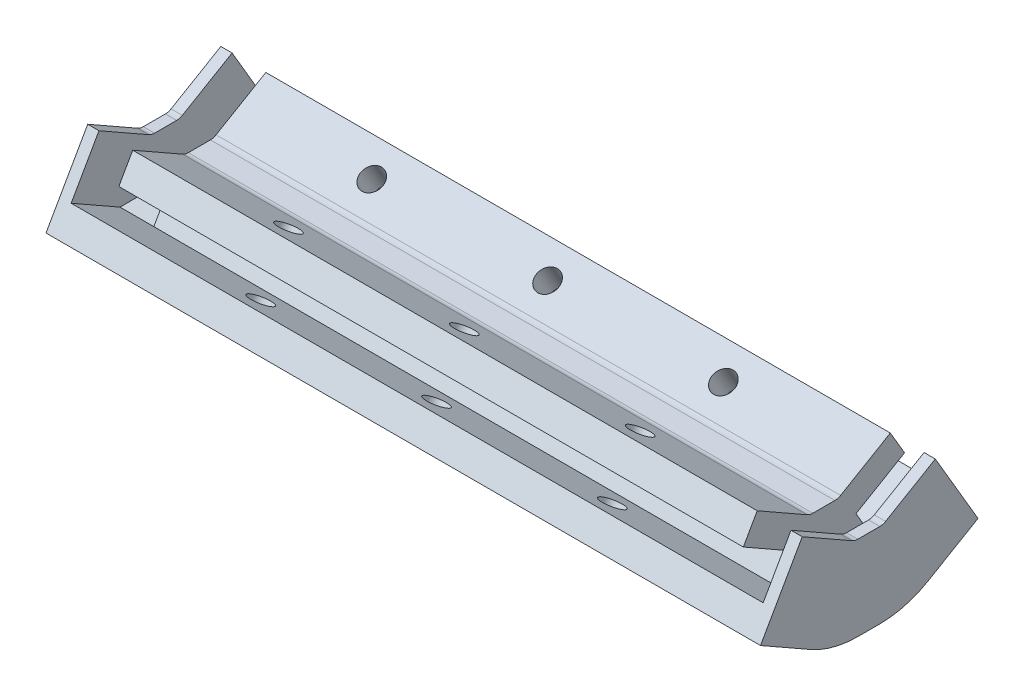
from build123d import *

# Parameters (mm, degrees)
SALIENTE_EXTRUIR1_DEPTH = 111
CROQUIS2_W              = 111
CROQUIS2_H              = 5
CORTAR_EXTRUIR1_DEPTH   = 5
CROQUIS3_W              = 111
CROQUIS3_H              = 5
CORTAR_EXTRUIR2_DEPTH   = 5
CROQUIS8_W              = 111
CROQUIS8_H              = 5
SALIENTE_EXTRUIR6_DEPTH = 5
CROQUIS9_W              = 111
CROQUIS9_H              = 5
SALIENTE_EXTRUIR7_DEPTH = 5
CROQUIS10_W             = 111
CROQUIS10_H             = 5
SALIENTE_EXTRUIR8_DEPTH = 5
CROQUIS11_W             = 111
CROQUIS11_H             = 5
SALIENTE_EXTRUIR9_DEPTH = 5
SALIENTE_EXTRUIR2_DEPTH = 8
SALIENTE_EXTRUIR3_DEPTH = 2
SALIENTE_EXTRUIR4_DEPTH = 8
SALIENTE_EXTRUIR5_DEPTH = 2
CROQUIS12_R             = 2
CORTAR_EXTRUIR3_DEPTH   = 16
CROQUIS13_R             = 4
CORTAR_EXTRUIR4_DEPTH   = 4
CROQUIS14_R             = 2
CORTAR_EXTRUIR5_DEPTH   = 16
CROQUIS15_R             = 4
CORTAR_EXTRUIR6_DEPTH   = 4


with BuildPart() as part:
    # Croquis1 → Saliente-Extruir1 (new body)
    with BuildSketch(Plane(origin=(0, 0, 0), x_dir=(0, 0, -1), z_dir=(1, 0, 0))):
        with BuildLine():
            Line((2.336042938, 2.185332004), (-2.204135338, 4.767752626))
            Line((-2.204135338, 4.767752626), (-7.148243501, -3.924530991))
            Line((-7.148243501, -3.924530991), (-2.608065225, -6.506951614))
            ThreePointArc((-2.608065225, -6.506951614), (0.256386453, -7.677264762), (3.32486457, -8.076211273))
            Line((3.32486457, -8.076211273), (7.253055883, -8.076211273))
            ThreePointArc((7.253055883, -8.076211273), (10.396202626, -7.657257363), (13.3198771, -6.429649364))
            Line((13.3198771, -6.429649364), (17.85154901, -3.774218091))
            Line((17.85154901, -3.774218091), (12.795864662, 4.853646985))
            Line((12.795864662, 4.853646985), (8.264192752, 2.198215712))
            ThreePointArc((8.264192752, 2.198215712), (7.776913673, 1.993614379), (7.253055883, 1.923788727))
            Line((7.253055883, 1.923788727), (3.32486457, 1.923788727))
            ThreePointArc((3.32486457, 1.923788727), (2.813451551, 1.990279812), (2.336042938, 2.185332004))
        make_face()
        with BuildLine():
            Line((-2.608065225, -6.506951614), (-7.148243501, -3.924530991))
            Line((-7.148243501, -3.924530991), (-9.620297582, -8.270672799))
            Line((-9.620297582, -8.270672799), (-5.080119306, -10.853093422))
            ThreePointArc((-5.080119306, -10.853093422), (-1.022146096, -12.511037048), (3.32486457, -13.076211273))
            Line((3.32486457, -13.076211273), (7.253055883, -13.076211273))
            ThreePointArc((7.253055883, -13.076211273), (11.705847103, -12.482693234), (15.847719275, -10.743581902))
            Line((15.847719275, -10.743581902), (20.379391184, -8.088150629))
            Line((20.379391184, -8.088150629), (17.85154901, -3.774218091))
            Line((17.85154901, -3.774218091), (13.3198771, -6.429649364))
            ThreePointArc((13.3198771, -6.429649364), (10.396202626, -7.657257363), (7.253055883, -8.076211273))
            Line((7.253055883, -8.076211273), (3.32486457, -8.076211273))
            ThreePointArc((3.32486457, -8.076211273), (0.256386453, -7.677264762), (-2.608065225, -6.506951614))
        make_face()
    extrude(amount=SALIENTE_EXTRUIR1_DEPTH)

    # Croquis2 → Cortar-Extruir1 (cut)
    with BuildSketch(Plane(origin=(0, 6.822115228, -11.642398074), x_dir=(1, 0, 0), z_dir=(0, 0.505568435, -0.862786508))):
        with Locations((55.5, 9.781524138)):
            Rectangle(CROQUIS2_W, CROQUIS2_H)
    extrude(amount=-CORTAR_EXTRUIR1_DEPTH, mode=Mode.SUBTRACT)

    # Croquis3 → Cortar-Extruir2 (cut)
    with BuildSketch(Plane(origin=(0, 2.112679425, 3.714321805), x_dir=(1, 0, 0), z_dir=(0, 0.494410816, 0.869228362))):
        with Locations((55.5, -4.445482547)):
            Rectangle(CROQUIS3_W, CROQUIS3_H)
    extrude(amount=-CORTAR_EXTRUIR2_DEPTH, mode=Mode.SUBTRACT)

    # Croquis8 → Saliente-Extruir6 (add)
    with BuildSketch(Plane(origin=(0, 2.112679425, 3.714321805), x_dir=(1, 0, 0), z_dir=(0, 0.494410816, 0.869228362))):
        with Locations((55.5, 0.554517453)):
            Rectangle(CROQUIS8_W, CROQUIS8_H)
    extrude(amount=SALIENTE_EXTRUIR6_DEPTH)

    # Croquis9 → Saliente-Extruir7 (add)
    with BuildSketch(Plane(origin=(0, 2.112679425, 3.714321805), x_dir=(1, 0, 0), z_dir=(0, 0.494410816, 0.869228362))):
        with Locations((55.5, -9.445482547)):
            Rectangle(CROQUIS9_W, CROQUIS9_H)
    extrude(amount=SALIENTE_EXTRUIR7_DEPTH)

    # Croquis10 → Saliente-Extruir8 (add)
    with BuildSketch(Plane(origin=(0, 6.822115228, -11.642398074), x_dir=(-1, 0, 0), z_dir=(0, 0.505568435, -0.862786508))):
        with Locations((-55.5, -4.781524138)):
            Rectangle(CROQUIS10_W, CROQUIS10_H)
    extrude(amount=SALIENTE_EXTRUIR8_DEPTH)

    # Croquis11 → Saliente-Extruir9 (add)
    with BuildSketch(Plane(origin=(0, 6.822115228, -11.642398074), x_dir=(-1, 0, 0), z_dir=(0, 0.505568435, -0.862786508))):
        with Locations((-55.5, -14.781524138)):
            Rectangle(CROQUIS11_W, CROQUIS11_H)
    extrude(amount=SALIENTE_EXTRUIR9_DEPTH)

    # Croquis4 → Saliente-Extruir2 (add)
    with BuildSketch(Plane.ZY):
        with BuildLine():
            Line((2.802101692, -6.396585072), (-13.537616472, -6.302060265))
            Line((-13.537616472, -6.302060265), (-22.165481548, -1.246375917))
            Line((-22.165481548, -1.246375917), (-24.693323722, -5.560308455))
            Line((-24.693323722, -5.560308455), (-15.847719275, -10.743581902))
            ThreePointArc((-15.847719275, -10.743581902), (-11.705847103, -12.482693234), (-7.253055883, -13.076211273))
            Line((-7.253055883, -13.076211273), (-3.32486457, -13.076211273))
            ThreePointArc((-3.32486457, -13.076211273), (1.022146096, -12.511037048), (5.080119306, -10.853093422))
            Line((5.080119306, -10.853093422), (13.96643939, -5.798618718))
            Line((13.96643939, -5.798618718), (11.494385309, -1.452476909))
            Line((11.494385309, -1.452476909), (2.802101692, -6.396585072))
        make_face()
    extrude(amount=SALIENTE_EXTRUIR2_DEPTH)

    # Croquis5 → Saliente-Extruir3 (add)
    with BuildSketch(Plane.ZY.offset(8)):
        with BuildLine():
            Line((-8.264192752, 2.198215712), (-17.1097972, 7.381489159))
            Line((-17.1097972, 7.381489159), (-22.165481548, -1.246375917))
            Line((-22.165481548, -1.246375917), (-13.537616472, -6.302060265))
            Line((-13.537616472, -6.302060265), (2.802101692, -6.396585072))
            Line((2.802101692, -6.396585072), (11.494385309, -1.452476909))
            Line((11.494385309, -1.452476909), (6.550277147, 7.239806708))
            Line((6.550277147, 7.239806708), (-2.336042938, 2.185332004))
            ThreePointArc((-2.336042938, 2.185332004), (-2.813451551, 1.990279812), (-3.32486457, 1.923788727))
            Line((-3.32486457, 1.923788727), (-7.253055883, 1.923788727))
            ThreePointArc((-7.253055883, 1.923788727), (-7.776913673, 1.993614379), (-8.264192752, 2.198215712))
        make_face()
    extrude(amount=-SALIENTE_EXTRUIR3_DEPTH)

    # Croquis6 → Saliente-Extruir4 (add)
    with BuildSketch(Plane(origin=(111, 0, 0), x_dir=(0, 0, -1), z_dir=(1, 0, 0))):
        with BuildLine():
            Line((13.537616472, -6.302060265), (-2.802101692, -6.396585072))
            Line((-2.802101692, -6.396585072), (-11.494385309, -1.452476909))
            Line((-11.494385309, -1.452476909), (-13.96643939, -5.798618718))
            Line((-13.96643939, -5.798618718), (-5.080119306, -10.853093422))
            ThreePointArc((-5.080119306, -10.853093422), (-1.022146096, -12.511037048), (3.32486457, -13.076211273))
            Line((3.32486457, -13.076211273), (7.253055883, -13.076211273))
            ThreePointArc((7.253055883, -13.076211273), (11.705847103, -12.482693234), (15.847719275, -10.743581902))
            Line((15.847719275, -10.743581902), (24.693323722, -5.560308455))
            Line((24.693323722, -5.560308455), (22.165481548, -1.246375917))
            Line((22.165481548, -1.246375917), (13.537616472, -6.302060265))
        make_face()
    extrude(amount=SALIENTE_EXTRUIR4_DEPTH)

    # Croquis7 → Saliente-Extruir5 (add)
    with BuildSketch(Plane(origin=(119, 0, 0), x_dir=(0, 0, -1), z_dir=(1, 0, 0))):
        with BuildLine():
            Line((22.165481548, -1.246375917), (17.1097972, 7.381489159))
            Line((17.1097972, 7.381489159), (8.264192752, 2.198215712))
            ThreePointArc((8.264192752, 2.198215712), (7.776913673, 1.993614379), (7.253055883, 1.923788727))
            Line((7.253055883, 1.923788727), (3.32486457, 1.923788727))
            ThreePointArc((3.32486457, 1.923788727), (2.813451551, 1.990279812), (2.336042938, 2.185332004))
            Line((2.336042938, 2.185332004), (-6.550277147, 7.239806708))
            Line((-6.550277147, 7.239806708), (-11.494385309, -1.452476909))
            Line((-11.494385309, -1.452476909), (-2.802101692, -6.396585072))
            Line((-2.802101692, -6.396585072), (13.537616472, -6.302060265))
            Line((13.537616472, -6.302060265), (22.165481548, -1.246375917))
        make_face()
    extrude(amount=-SALIENTE_EXTRUIR5_DEPTH)

    # Croquis12 → Cortar-Extruir3 (cut)
    with BuildSketch(Plane(origin=(0, -10.383352224, 5.905975776), x_dir=(-1, 0, 0), z_dir=(0, -0.869228362, 0.494410816))):
        with Locations((-23.25, -4.16151121)):
            Circle(CROQUIS12_R)
        with Locations((-54.5, -4.16151121)):
            Circle(CROQUIS12_R)
        with Locations((-85.75, -4.16151121)):
            Circle(CROQUIS12_R)
    extrude(amount=-CORTAR_EXTRUIR3_DEPTH, mode=Mode.SUBTRACT)

    # Croquis13 → Cortar-Extruir4 (cut)
    with BuildSketch(Plane(origin=(0, -10.383352224, 5.905975776), x_dir=(1, 0, 0), z_dir=(0, -0.869228362, 0.494410816))):
        with Locations((23.25, 4.16151121)):
            Circle(CROQUIS13_R)
        with Locations((54.5, 4.16151121)):
            Circle(CROQUIS13_R)
        with Locations((85.75, 4.16151121)):
            Circle(CROQUIS13_R)
    extrude(amount=-CORTAR_EXTRUIR4_DEPTH, mode=Mode.SUBTRACT)

    # Croquis14 → Cortar-Extruir5 (cut)
    with BuildSketch(Plane(origin=(0, -14.910265857, -8.73699311), x_dir=(-1, 0, 0), z_dir=(0, -0.862786508, -0.505568435))):
        with Locations((-23.25, 13.367766286)):
            Circle(CROQUIS14_R)
        with Locations((-54.5, 13.367766286)):
            Circle(CROQUIS14_R)
        with Locations((-85.75, 13.367766286)):
            Circle(CROQUIS14_R)
    extrude(amount=-CORTAR_EXTRUIR5_DEPTH, mode=Mode.SUBTRACT)

    # Croquis15 → Cortar-Extruir6 (cut)
    with BuildSketch(Plane(origin=(0, -14.910265857, -8.73699311), x_dir=(1, 0, 0), z_dir=(0, -0.862786508, -0.505568435))):
        with Locations((23.25, -13.367766286)):
            Circle(CROQUIS15_R)
        with Locations((54.5, -13.367766286)):
            Circle(CROQUIS15_R)
        with Locations((85.75, -13.367766286)):
            Circle(CROQUIS15_R)
    extrude(amount=-CORTAR_EXTRUIR6_DEPTH, mode=Mode.SUBTRACT)


solid = part.part
